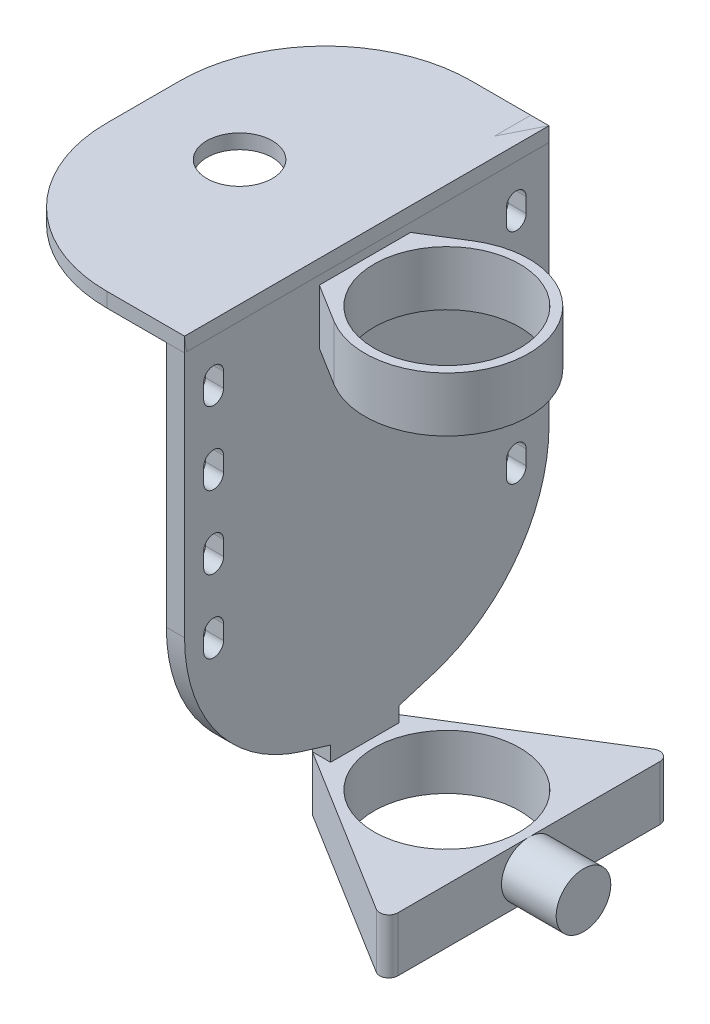
from build123d import *

# Parameters (mm, degrees)
SKETCH1_R              = 4.5
SKETCH1_R_2            = 4
BOSS_EXTRUDE1_DEPTH    = 1.5
BOSS_EXTRUDE2_REACH    = 14
SKETCH4_R              = 1.5
BOSS_EXTRUDE3_DEPTH    = 1
FILLET1_R              = 9
CUT_EXTRUDE1_DEPTH     = 1
LPATTERN1_COUNT        = 4
LPATTERN1_PITCH        = 4
LPATTERN1_COPY_1_DEPTH = 1
LPATTERN1_COPY_2_DEPTH = 1
LPATTERN1_COPY_3_DEPTH = 1
SKETCH8_W              = 12.26701151
SKETCH8_H              = 0.8
BOSS_EXTRUDE4_DEPTH    = 20.008657
FILLET3_R              = 8
SKETCH9_R              = 4
BOSS_EXTRUDE5_DEPTH    = 3
FILLET5_R              = 0.5
SKETCH11_R             = 4.5
SKETCH11_R_2           = 4
BOSS_EXTRUDE6_DEPTH    = 3
BOSS_EXTRUDE7_DEPTH    = 3
SKETCH10_R             = 1.798339867
CUT_EXTRUDE3_DEPTH     = 1


with BuildPart() as part:
    # Sketch1 → Boss-Extrude1 (new body, symmetric)
    with BuildSketch(Plane(origin=(0, 0, 0), x_dir=(1, 0, 0), z_dir=(0, 1, 0))):
        Circle(SKETCH1_R)
        Circle(SKETCH1_R_2, mode=Mode.SUBTRACT)
    extrude(amount=BOSS_EXTRUDE1_DEPTH, both=True)

    # Sketch4 → Boss-Extrude2 (add, up to next)
    with BuildSketch(Plane(origin=(7.5, 0, 0), x_dir=(0, 0, -1), z_dir=(1, 0, 0)), mode=Mode.PRIVATE) as boss_extrude2_sk1:
        Circle(SKETCH4_R)
    boss_extrude2_tool1 = extrude(boss_extrude2_sk1.sketch, amount=-BOSS_EXTRUDE2_REACH, mode=Mode.PRIVATE) - part.part
    add(boss_extrude2_tool1.solids().sort_by_distance((7.5, 0, 0))[0])

    # Sketch9 → Boss-Extrude5 (add)
    with BuildSketch(Plane.XZ.offset(1.5)):
        Polygon((4.5, 8.085472141), (4.5, -8.085472141), (-5.5, -1.884383055), (-5.5, 1.884383055), align=None)
        Circle(SKETCH9_R, mode=Mode.SUBTRACT)
    extrude(amount=-BOSS_EXTRUDE5_DEPTH)

    # Fillet5
    fillet5_edges = [part.edges().sort_by_distance(p)[0] for p in [
        (4.5, 0, -8.085472141),
        (4.5, 0, 8.085472141),
    ]]
    fillet(fillet5_edges, radius=FILLET5_R)


with BuildPart() as body_2:
    # Sketch6 → Boss-Extrude3 (new body)
    with BuildSketch(Plane(origin=(-4.5, 0, 0), x_dir=(0, 0, -1), z_dir=(1, 0, 0))):
        Polygon((1.884383055, -1.5), (1.884383055, 2.322252785), (10.105735978, 4.835772616), (10.105735978, 25.773765949), (-9.90292131, 25.773765949), (-9.90292131, 4.773765949), (-1.884383055, 2.322252785), (-1.884383055, -1.5), align=None)
    extrude(amount=-BOSS_EXTRUDE3_DEPTH)

    # Fillet1
    fillet1_edges = [body_2.edges().sort_by_distance(p)[0] for p in [
        (-5, 4.773765949, 9.90292131),
        (-5, 4.835772616, -10.105735978),
    ]]
    fillet(fillet1_edges, radius=FILLET1_R)

    # Sketch7 → Cut-Extrude1 (cut)
    with BuildSketch(Plane.ZY.offset(5.5)):
        with BuildLine():
            Line((-7.761048452, 23.030820996), (-7.761048452, 22.230820996))
            ThreePointArc((-7.761048452, 22.230820996), (-8.306666723, 21.685202725), (-8.852284995, 22.230820996))
            Line((-8.852284995, 22.230820996), (-8.852284995, 23.030820996))
            ThreePointArc((-8.852284995, 23.030820996), (-8.306666723, 23.576439267), (-7.761048452, 23.030820996))
        make_face()
    cut_extrude1 = extrude(amount=-CUT_EXTRUDE1_DEPTH, mode=Mode.SUBTRACT)

    # Mirror1: Cut-Extrude1 across plane
    add(cut_extrude1.mirror(Plane.XY), mode=Mode.SUBTRACT)

    # LPattern1: Cut-Extrude1 ×4
    with Locations(*[(0, -i * LPATTERN1_PITCH, 0) for i in range(1, LPATTERN1_COUNT)]):
        add(cut_extrude1, mode=Mode.SUBTRACT)

    # LPattern1 copy 1 sketch → LPattern1 copy 1 (cut)
    with BuildSketch(Plane(origin=(-5.5, -4, 0), x_dir=(0, 0, -1), z_dir=(-1, 0, 0))):
        with BuildLine():
            Line((-7.761048452, -23.030820996), (-7.761048452, -22.230820996))
            ThreePointArc((-7.761048452, -22.230820996), (-8.306666723, -21.685202725), (-8.852284995, -22.230820996))
            Line((-8.852284995, -22.230820996), (-8.852284995, -23.030820996))
            ThreePointArc((-8.852284995, -23.030820996), (-8.306666723, -23.576439267), (-7.761048452, -23.030820996))
        make_face()
    extrude(amount=-LPATTERN1_COPY_1_DEPTH, mode=Mode.SUBTRACT)

    # LPattern1 copy 2 sketch → LPattern1 copy 2 (cut)
    with BuildSketch(Plane(origin=(-5.5, -8, 0), x_dir=(0, 0, -1), z_dir=(-1, 0, 0))):
        with BuildLine():
            Line((-7.761048452, -23.030820996), (-7.761048452, -22.230820996))
            ThreePointArc((-7.761048452, -22.230820996), (-8.306666723, -21.685202725), (-8.852284995, -22.230820996))
            Line((-8.852284995, -22.230820996), (-8.852284995, -23.030820996))
            ThreePointArc((-8.852284995, -23.030820996), (-8.306666723, -23.576439267), (-7.761048452, -23.030820996))
        make_face()
    extrude(amount=-LPATTERN1_COPY_2_DEPTH, mode=Mode.SUBTRACT)

    # LPattern1 copy 3 sketch → LPattern1 copy 3 (cut)
    with BuildSketch(Plane(origin=(-5.5, -12, 0), x_dir=(0, 0, -1), z_dir=(-1, 0, 0))):
        with BuildLine():
            Line((-7.761048452, -23.030820996), (-7.761048452, -22.230820996))
            ThreePointArc((-7.761048452, -22.230820996), (-8.306666723, -21.685202725), (-8.852284995, -22.230820996))
            Line((-8.852284995, -22.230820996), (-8.852284995, -23.030820996))
            ThreePointArc((-8.852284995, -23.030820996), (-8.306666723, -23.576439267), (-7.761048452, -23.030820996))
        make_face()
    extrude(amount=-LPATTERN1_COPY_3_DEPTH, mode=Mode.SUBTRACT)



with BuildPart() as body_3:
    # Sketch8 → Boss-Extrude4 (new body)
    with BuildSketch(Plane(origin=(0, 0, -10.105735978), x_dir=(-1, 0, 0), z_dir=(0, 0, -1))):
        with Locations((10.633505755, 25.373765949)):
            Rectangle(SKETCH8_W, SKETCH8_H)
    extrude(amount=-BOSS_EXTRUDE4_DEPTH)

    # Fillet3
    fillet3_edges = [body_3.edges().sort_by_distance(p)[0] for p in [
        (-16.76701151, 25.373765949, -10.105735978),
        (-16.76701151, 25.373765949, 9.902921022),
    ]]
    fillet(fillet3_edges, radius=FILLET3_R)

    # Sketch10 → Cut-Extrude3 (cut)
    with BuildSketch(Plane.XZ.offset(-24.973765949)):
        with Locations((-11.383014104, 0)):
            Circle(SKETCH10_R)
    extrude(amount=-CUT_EXTRUDE3_DEPTH, mode=Mode.SUBTRACT)


with BuildPart() as body_4:
    # Sketch11 → Boss-Extrude6 (new body)
    with BuildSketch(Plane(origin=(0, 21.5, 0), x_dir=(1, 0, 0), z_dir=(0, 1, 0))):
        Circle(SKETCH11_R)
        Circle(SKETCH11_R_2, mode=Mode.SUBTRACT)
    extrude(amount=BOSS_EXTRUDE6_DEPTH)


with BuildPart() as body_2_1:
    add(body_2.part)

    add(body_4.part)  # Boss-Extrude7 merges body 4
    # Sketch13 → Boss-Extrude7 (add)
    with BuildSketch(Plane(origin=(0, 24.5, 0), x_dir=(1, 0, 0), z_dir=(0, 1, 0))):
        with BuildLine():
            Line((-5.5, 1.884383055), (-2.37152936, 3.824375569))
            ThreePointArc((-2.37152936, 3.824375569), (-4.5, 0), (-2.37152936, -3.824375569))
            Line((-2.37152936, -3.824375569), (-5.5, -1.884383055))
            Line((-5.5, -1.884383055), (-5.5, 1.884383055))
        make_face()
    extrude(amount=-BOSS_EXTRUDE7_DEPTH)


solid = Compound([part.part, body_3.part, body_2_1.part])
